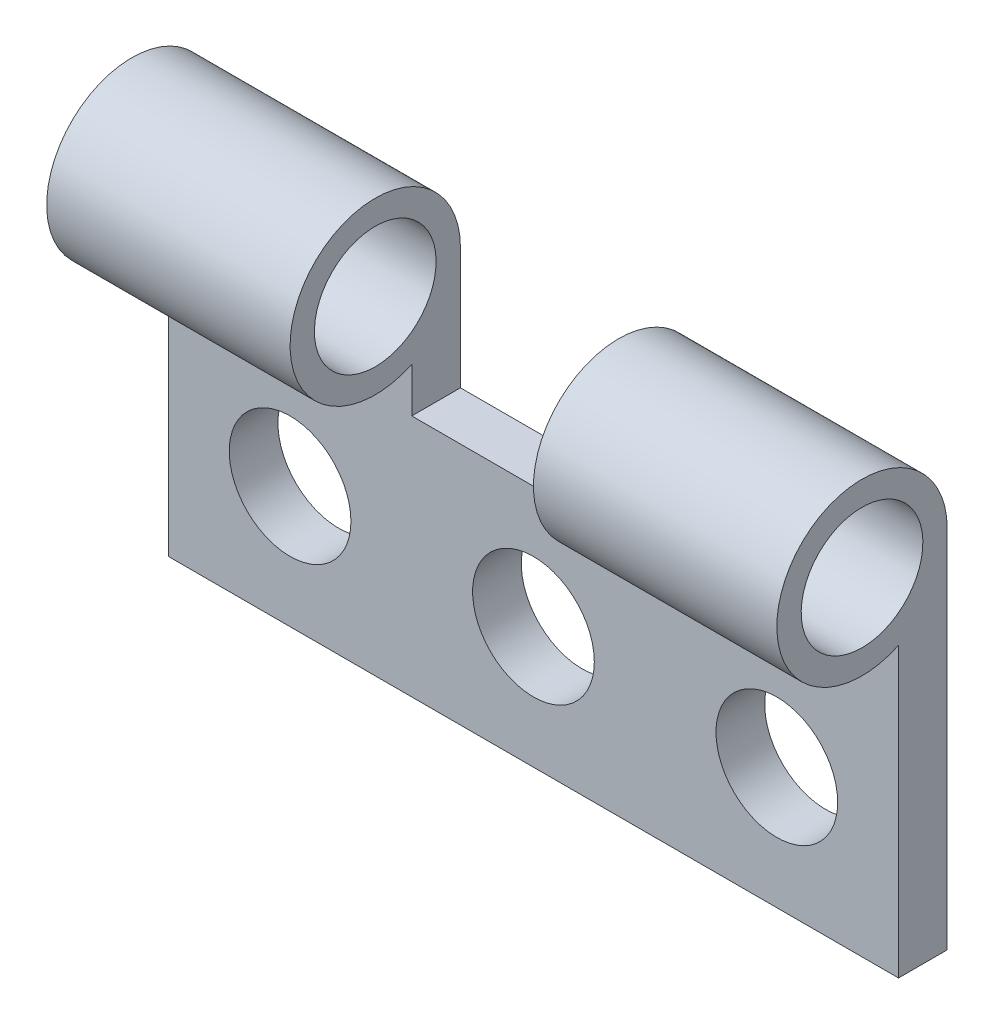
from build123d import *

# Parameters (mm, degrees)
SKETCH1_W           = 30
SKETCH1_H           = 10
BOSS_EXTRUDE1_DEPTH = 2
SKETCH2_R           = 2.5
BOSS_EXTRUDE2_DEPTH = 10
LPATTERN1_COUNT     = 2
LPATTERN1_PITCH     = 20
SKETCH3_R           = 2.5
CUT_EXTRUDE1_DEPTH  = 10


with BuildPart() as part:
    # Sketch1 → Boss-Extrude1 (new body)
    with BuildSketch(Plane.XY):
        Rectangle(SKETCH1_W, SKETCH1_H)
    extrude(amount=BOSS_EXTRUDE1_DEPTH)

    # Sketch2 → Boss-Extrude2 (add)
    with BuildSketch(Plane.ZY.offset(15)):
        with BuildLine():
            Line((0, 5), (0, 10))
            ThreePointArc((0, 10), (6.458039892, 11.870828693), (2, 6.83772234))
            Line((2, 6.83772234), (2, 5))
            Line((2, 5), (0, 5))
        make_face()
        with Locations((3.5, 10)):
            Circle(SKETCH2_R, mode=Mode.SUBTRACT)
    boss_extrude2 = extrude(amount=-BOSS_EXTRUDE2_DEPTH)

    # LPattern1: Boss-Extrude2 ×2
    with Locations(*[(i * LPATTERN1_PITCH, 0, 0) for i in range(1, LPATTERN1_COUNT)]):
        add(boss_extrude2)

    # Sketch3 → Cut-Extrude1 (cut)
    with BuildSketch(Plane.XY.offset(2)):
        with Locations((-10, 0)):
            Circle(SKETCH3_R)
        Circle(SKETCH3_R)
        with Locations((10, 0)):
            Circle(SKETCH3_R)
    extrude(amount=-CUT_EXTRUDE1_DEPTH, mode=Mode.SUBTRACT)


solid = part.part
